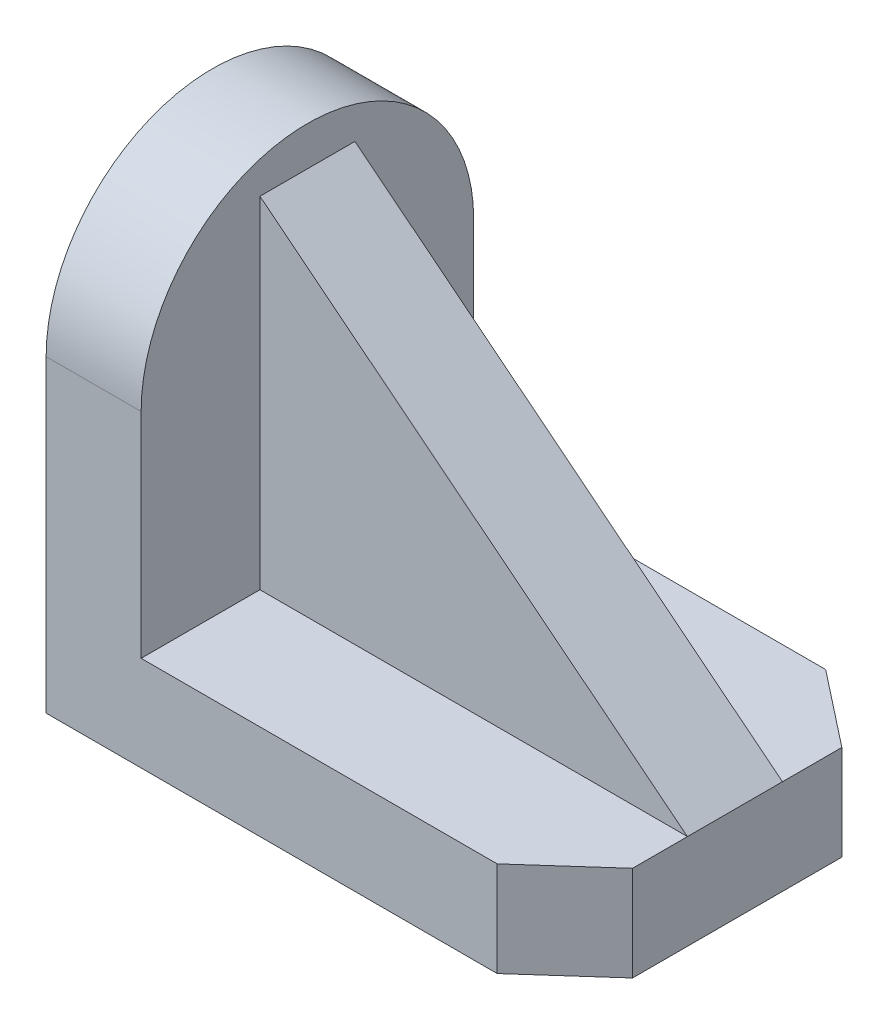
from build123d import *

# Parameters (mm, degrees)
SKETCH1_W           = 66
SKETCH1_H           = 42
BOSS_EXTRUDE1_DEPTH = 12
SKETCH2_W           = 12
SKETCH2_H           = 42
BOSS_EXTRUDE2_DEPTH = 26.995042498
SKETCH4_R           = 21
BOSS_EXTRUDE8_DEPTH = 12
BOSS_EXTRUDE9_DEPTH = 6
CUT_EXTRUDE1_DEPTH  = 12


with BuildPart() as part:
    # Sketch1 → Boss-Extrude1 (new body)
    with BuildSketch(Plane(origin=(0, 0, 0), x_dir=(1, 0, 0), z_dir=(0, 1, 0))):
        Rectangle(SKETCH1_W, SKETCH1_H)
    extrude(amount=BOSS_EXTRUDE1_DEPTH)

    # Sketch2 → Boss-Extrude2 (add)
    with BuildSketch(Plane(origin=(0, 12, 0), x_dir=(1, 0, 0), z_dir=(0, 1, 0))):
        with Locations((-27, 0)):
            Rectangle(SKETCH2_W, SKETCH2_H)
    extrude(amount=BOSS_EXTRUDE2_DEPTH)

    # Sketch4 → Boss-Extrude8 (add)
    with BuildSketch(Plane(origin=(-21, 0, 0), x_dir=(0, 0, -1), z_dir=(1, 0, 0))):
        with Locations((0, 38.995042498)):
            Circle(SKETCH4_R)
    extrude(amount=-BOSS_EXTRUDE8_DEPTH)

    # Sketch8 → Boss-Extrude9 (add, symmetric)
    with BuildSketch(Plane.XY):
        Polygon((-21, 12), (-21, 55.038969321), (33, 12), align=None)
    extrude(amount=BOSS_EXTRUDE9_DEPTH, both=True)

    # Sketch12 → Cut-Extrude1 (cut)
    with BuildSketch(Plane(origin=(0, 12, 0), x_dir=(1, 0, 0), z_dir=(0, 1, 0))):
        Polygon((33, -12.935780303), (33, -21), (23.965356614, -21), align=None)
        Polygon((33, 13.5), (33, 21), (23.455136658, 21), align=None)
    extrude(amount=-CUT_EXTRUDE1_DEPTH, mode=Mode.SUBTRACT)


solid = part.part
